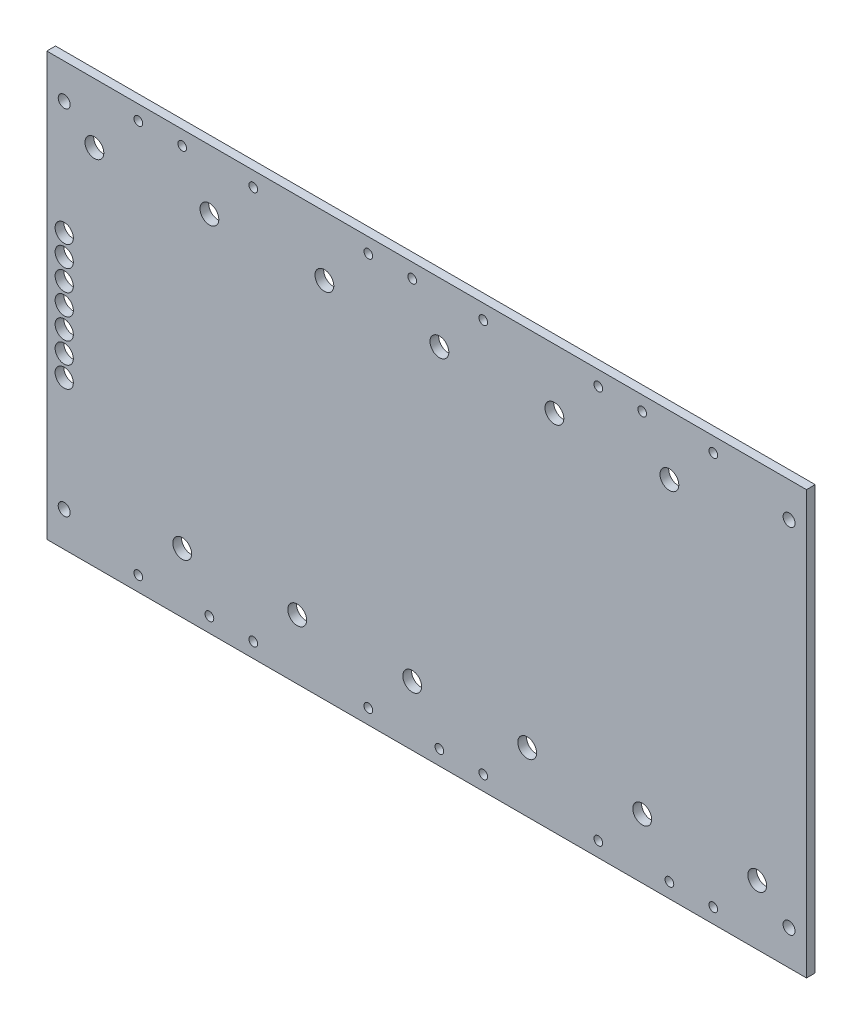
from build123d import *

# Parameters (mm, degrees)
SKETCH1_R           = 0.79375
SKETCH1_R_2         = 1.7145
SKETCH1_R_3         = 1.0922
SKETCH1_R_4         = 1.659299133
BOSS_EXTRUDE1_DEPTH = 1.5875


with BuildPart() as part:
    # Sketch1 → Boss-Extrude1 (new body)
    with BuildSketch(Plane.XY):
        Polygon((0, 0), (132.08, 0), (132.08, 77.0636), (0, 77.0636), (-6.35, 77.0636), (-6.35, 0), align=None)
        with Locations((10.3251, 74.3712)):
            Circle(SKETCH1_R, mode=Mode.SUBTRACT)
        with Locations((10.3251, 2.6924)):
            Circle(SKETCH1_R, mode=Mode.SUBTRACT)
        with Locations((2.3241, 66.1543)):
            Circle(SKETCH1_R_2, mode=Mode.SUBTRACT)
        with Locations((18.3261, 74.4347)):
            Circle(SKETCH1_R, mode=Mode.SUBTRACT)
        with Locations((18.3261, 10.9093)):
            Circle(SKETCH1_R_2, mode=Mode.SUBTRACT)
        with Locations((23.2791, 66.1543)):
            Circle(SKETCH1_R_2, mode=Mode.SUBTRACT)
        with Locations((31.2801, 74.3712)):
            Circle(SKETCH1_R, mode=Mode.SUBTRACT)
        with Locations((31.2801, 2.6924)):
            Circle(SKETCH1_R, mode=Mode.SUBTRACT)
        with Locations((39.2811, 10.9093)):
            Circle(SKETCH1_R_2, mode=Mode.SUBTRACT)
        with Locations((65.1891, 66.1543)):
            Circle(SKETCH1_R_2, mode=Mode.SUBTRACT)
        with Locations((73.1901, 2.6924)):
            Circle(SKETCH1_R, mode=Mode.SUBTRACT)
        with Locations((81.1911, 10.9093)):
            Circle(SKETCH1_R_2, mode=Mode.SUBTRACT)
        with Locations((73.1901, 74.3712)):
            Circle(SKETCH1_R, mode=Mode.SUBTRACT)
        with Locations((65.1891, 2.6924)):
            Circle(SKETCH1_R, mode=Mode.SUBTRACT)
        with Locations((52.2351, 74.3712)):
            Circle(SKETCH1_R, mode=Mode.SUBTRACT)
        with Locations((44.2341, 66.1543)):
            Circle(SKETCH1_R_2, mode=Mode.SUBTRACT)
        with Locations((-3.175, 70.7136)):
            Circle(SKETCH1_R_3, mode=Mode.SUBTRACT)
        with Locations((-3.175, 6.35)):
            Circle(SKETCH1_R_3, mode=Mode.SUBTRACT)
        with Locations((60.2361, 10.9093)):
            Circle(SKETCH1_R_2, mode=Mode.SUBTRACT)
        with Locations((52.2351, 2.6924)):
            Circle(SKETCH1_R, mode=Mode.SUBTRACT)
        with Locations((107.0991, 66.1543)):
            Circle(SKETCH1_R_2, mode=Mode.SUBTRACT)
        with Locations((115.1001, 2.6924)):
            Circle(SKETCH1_R, mode=Mode.SUBTRACT)
        with Locations((123.1011, 10.9093)):
            Circle(SKETCH1_R_2, mode=Mode.SUBTRACT)
        with Locations((60.2361, 74.4347)):
            Circle(SKETCH1_R, mode=Mode.SUBTRACT)
        with Locations((102.1461, 74.4347)):
            Circle(SKETCH1_R, mode=Mode.SUBTRACT)
        with Locations((94.1451, 74.3712)):
            Circle(SKETCH1_R, mode=Mode.SUBTRACT)
        with Locations((86.1441, 66.1543)):
            Circle(SKETCH1_R_2, mode=Mode.SUBTRACT)
        with Locations((102.1461, 10.9093)):
            Circle(SKETCH1_R_2, mode=Mode.SUBTRACT)
        with Locations((94.1451, 2.6924)):
            Circle(SKETCH1_R, mode=Mode.SUBTRACT)
        with Locations((128.905, 70.7136)):
            Circle(SKETCH1_R_3, mode=Mode.SUBTRACT)
        with Locations((128.905, 6.35)):
            Circle(SKETCH1_R_3, mode=Mode.SUBTRACT)
        with Locations((23.2791, 2.6924)):
            Circle(SKETCH1_R, mode=Mode.SUBTRACT)
        with Locations((115.1001, 74.3712)):
            Circle(SKETCH1_R, mode=Mode.SUBTRACT)
        with Locations((107.0991, 2.6924)):
            Circle(SKETCH1_R, mode=Mode.SUBTRACT)
        with Locations((-3.175, 38.5318)):
            Circle(SKETCH1_R_4, mode=Mode.SUBTRACT)
        with Locations((-3.175, 42.3418)):
            Circle(SKETCH1_R_4, mode=Mode.SUBTRACT)
        with Locations((-3.175, 46.1518)):
            Circle(SKETCH1_R_4, mode=Mode.SUBTRACT)
        with Locations((-3.175, 49.9618)):
            Circle(SKETCH1_R_4, mode=Mode.SUBTRACT)
        with Locations((-3.175, 34.7218)):
            Circle(SKETCH1_R_4, mode=Mode.SUBTRACT)
        with Locations((-3.175, 30.9118)):
            Circle(SKETCH1_R_4, mode=Mode.SUBTRACT)
        with Locations((-3.175, 27.1018)):
            Circle(SKETCH1_R_4, mode=Mode.SUBTRACT)
    extrude(amount=BOSS_EXTRUDE1_DEPTH)


solid = part.part
